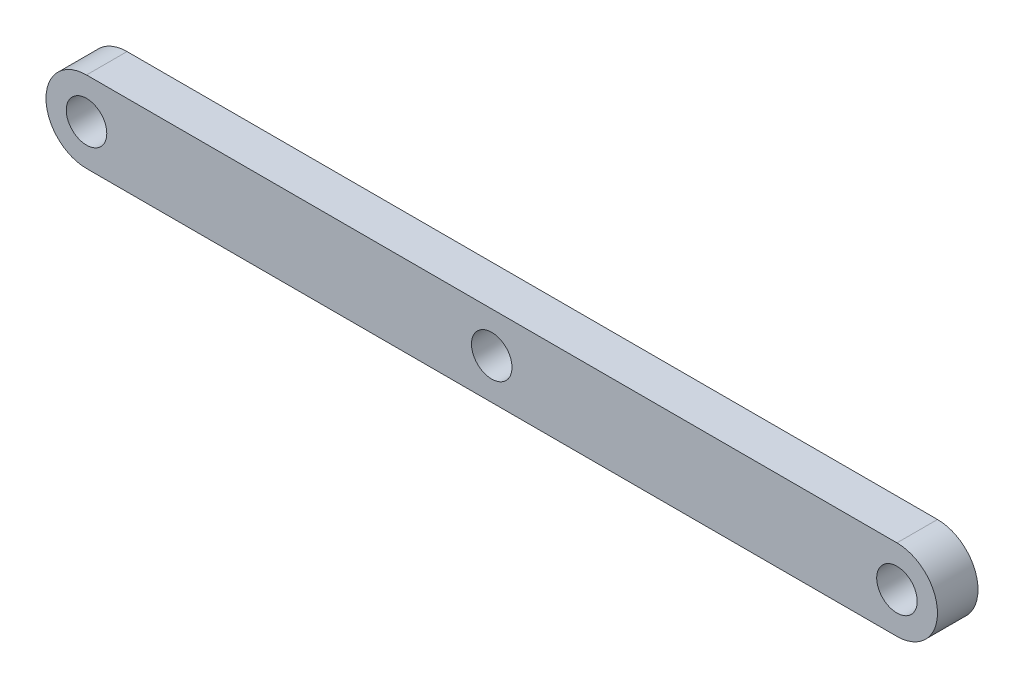
from build123d import *

# Parameters (mm, degrees)
SKETCH_2_R      = 5
EXTRUDE_1_DEPTH = 10


with BuildPart() as part:
    # 草图2 → 凸台-拉伸1 (new body)
    with BuildSketch(Plane.XY):
        with BuildLine():
            Line((0, 10), (200, 10))
            ThreePointArc((200, 10), (210, 0), (200, -10))
            Line((200, -10), (0, -10))
            ThreePointArc((0, -10), (-10, 0), (0, 10))
        make_face()
        Circle(SKETCH_2_R, mode=Mode.SUBTRACT)
        with Locations((200, 0)):
            Circle(SKETCH_2_R, mode=Mode.SUBTRACT)
        with Locations((100, 0)):
            Circle(SKETCH_2_R, mode=Mode.SUBTRACT)
    extrude(amount=EXTRUDE_1_DEPTH)


solid = part.part
